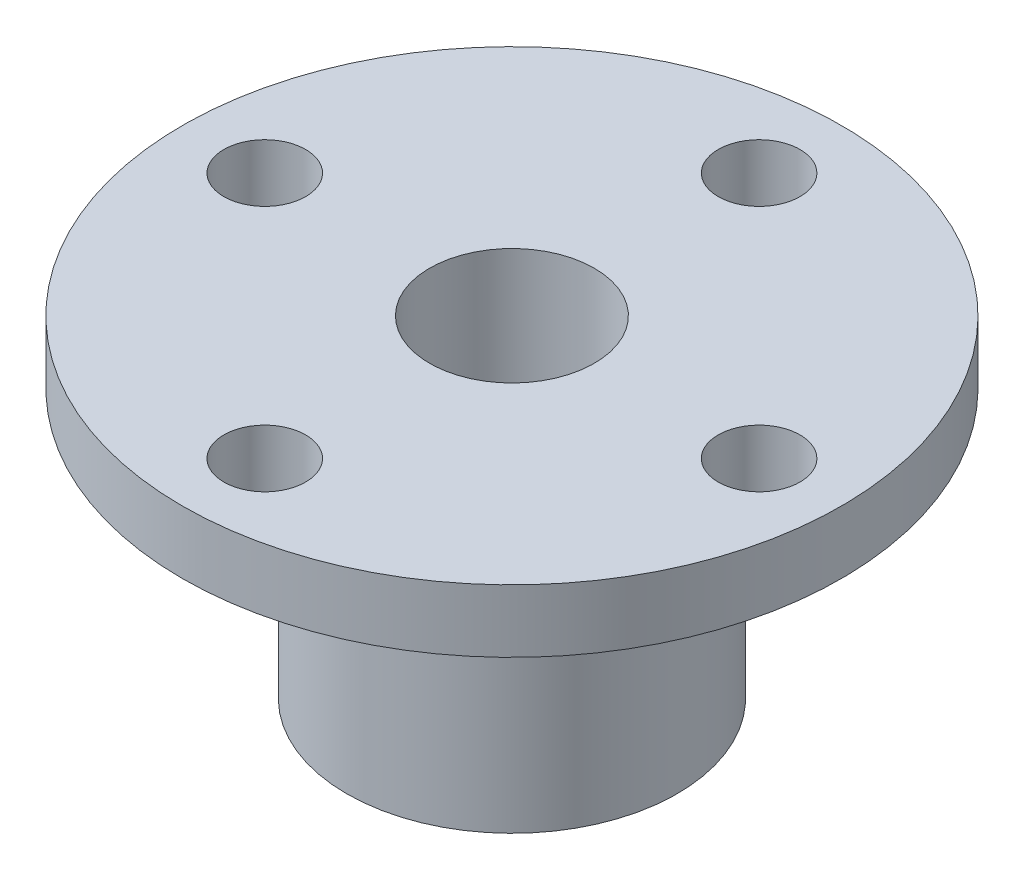
from build123d import *

# Parameters (mm, degrees)
SKETCH1_R           = 8.02
SKETCH1_R_2         = 4
BOSS_EXTRUDE1_DEPTH = 13.04
SKETCH2_R           = 16
BOSS_EXTRUDE2_DEPTH = 3.05
SKETCH3_R           = 4
CUT_EXTRUDE1_DEPTH  = 4.05
SKETCH4_R           = 1.985
CUT_EXTRUDE2_DEPTH  = 17.09


with BuildPart() as part:
    # Sketch1 → Boss-Extrude1 (new body)
    with BuildSketch(Plane(origin=(0, 0, 0), x_dir=(1, 0, 0), z_dir=(0, 1, 0))):
        Circle(SKETCH1_R)
        Circle(SKETCH1_R_2, mode=Mode.SUBTRACT)
    extrude(amount=BOSS_EXTRUDE1_DEPTH)

    # Sketch2 → Boss-Extrude2 (add)
    with BuildSketch(Plane(origin=(0, 13.04, 0), x_dir=(1, 0, 0), z_dir=(0, 1, 0))):
        Circle(SKETCH2_R)
    extrude(amount=BOSS_EXTRUDE2_DEPTH)

    # Sketch3 → Cut-Extrude1 (cut, through all)
    with BuildSketch(Plane.XZ.offset(-13.04)):
        Circle(SKETCH3_R)
    extrude(amount=-CUT_EXTRUDE1_DEPTH, mode=Mode.SUBTRACT)

    # Sketch4 → Cut-Extrude2 (cut, through all)
    with BuildSketch(Plane(origin=(0, 16.09, 0), x_dir=(1, 0, 0), z_dir=(0, 1, 0))):
        with Locations((-12, 0)):
            Circle(SKETCH4_R)
        with Locations((0, 12)):
            Circle(SKETCH4_R)
        with Locations((12, 0)):
            Circle(SKETCH4_R)
        with Locations((0, -12)):
            Circle(SKETCH4_R)
    extrude(amount=-CUT_EXTRUDE2_DEPTH, mode=Mode.SUBTRACT)


solid = part.part
